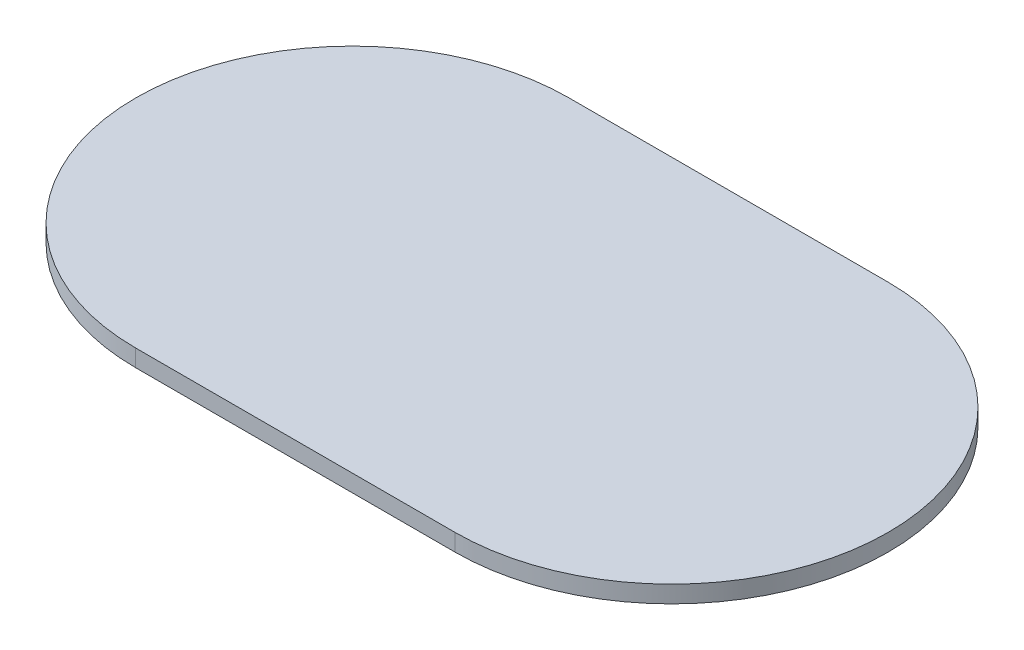
from build123d import *

# Parameters (mm, degrees)
BOSS_EXTRUDE1_DEPTH = 3


with BuildPart() as part:
    # Sketch2 → Boss-Extrude1 (new body)
    with BuildSketch(Plane(origin=(0, 0, 0), x_dir=(1, 0, 0), z_dir=(0, 1, 0))):
        with BuildLine():
            Line((-28, 38), (28, 38))
            ThreePointArc((28, 38), (66, 0), (28, -38))
            Line((28, -38), (-28, -38))
            ThreePointArc((-28, -38), (-66, 0), (-28, 38))
        make_face()
    extrude(amount=BOSS_EXTRUDE1_DEPTH)


solid = part.part
